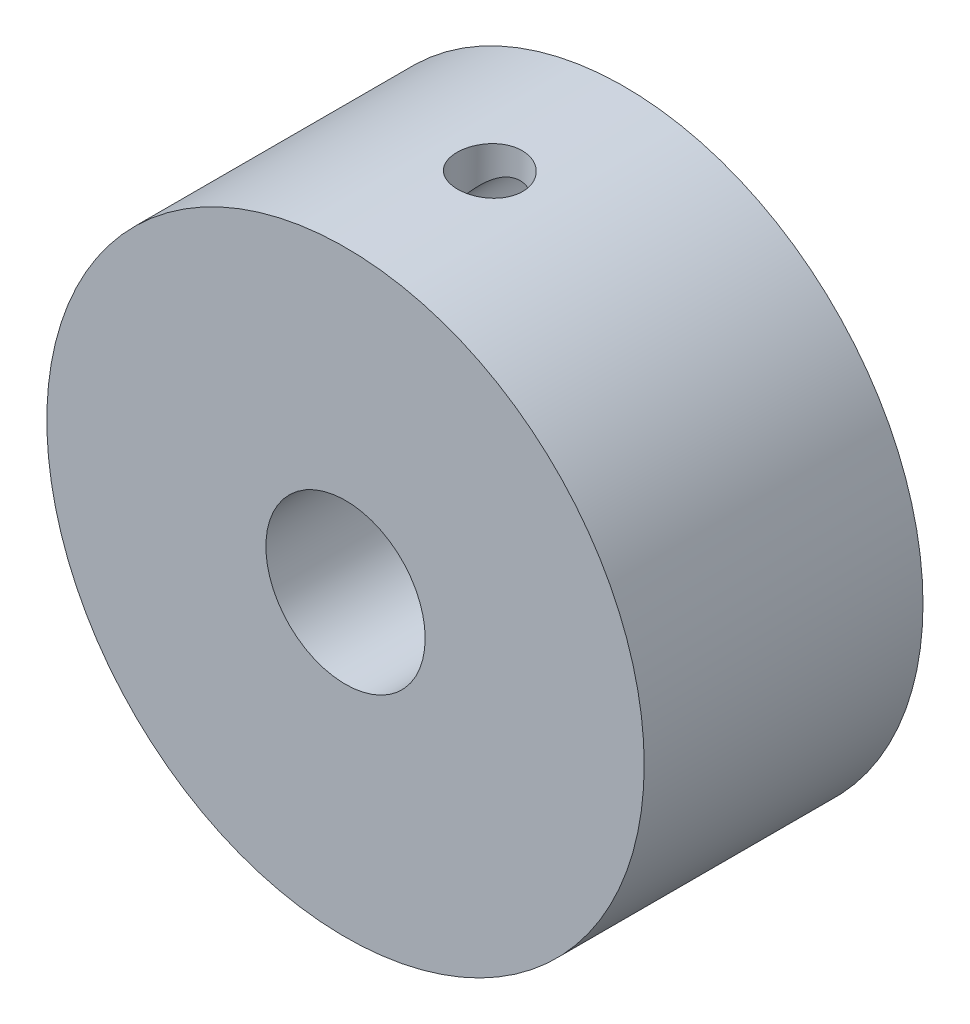
from build123d import *

# Parameters (mm, degrees)
SKETCH1_R                  = 15
SKETCH1_R_2                = 4
BOSS_EXTRUDE1_DEPTH        = 14
M4X0_7_TAPPED_HOLE1_REACH  = 36.371
M4X0_7_TAPPED_HOLE1_BORE_R = 1.65
M4X0_7_TAPPED_HOLE3_D      = 3.3
M4X0_7_TAPPED_HOLE3_DEPTH  = 8
M4X0_7_TAPPED_HOLE3_TIP    = 0.991420021


with BuildPart() as part:
    # Sketch1 → Boss-Extrude1 (new body)
    with BuildSketch(Plane.XY):
        Circle(SKETCH1_R)
        Circle(SKETCH1_R_2, mode=Mode.SUBTRACT)
    extrude(amount=BOSS_EXTRUDE1_DEPTH)

    # M4x0.7 Tapped Hole1 bore (on position points) → M4x0.7 Tapped Hole1 (cut, up to next)
    with BuildSketch(Plane(origin=(0.246830438, 14.99796902, 7), x_dir=(0.999864601356, -0.016455362532, 0), z_dir=(0.016455362532, 0.999864601356, 0)), mode=Mode.PRIVATE) as m4x0_7_tapped_hole1_sk1:
        Circle(M4X0_7_TAPPED_HOLE1_BORE_R)
    m4x0_7_tapped_hole1_tool1 = extrude(m4x0_7_tapped_hole1_sk1.sketch, amount=-M4X0_7_TAPPED_HOLE1_REACH, mode=Mode.PRIVATE) & part.part
    add(m4x0_7_tapped_hole1_tool1.solids().sort_by_distance((0.24683, 14.997969, 7))[0], mode=Mode.SUBTRACT)

    # M4x0.7 Tapped Hole3
    with Locations(Plane(origin=(0, 0, 0), x_dir=(-1, 0, 0), z_dir=(0, 0, -1))):
        with Locations((0, 12), (-12, 0), (0, -12), (12, 0)):
            Hole(M4X0_7_TAPPED_HOLE3_D / 2, depth=M4X0_7_TAPPED_HOLE3_DEPTH)
            with Locations((0, 0, -(M4X0_7_TAPPED_HOLE3_DEPTH + M4X0_7_TAPPED_HOLE3_TIP / 2))):  # 118° drill point
                Cone(0, M4X0_7_TAPPED_HOLE3_D / 2, M4X0_7_TAPPED_HOLE3_TIP, mode=Mode.SUBTRACT)


solid = part.part
